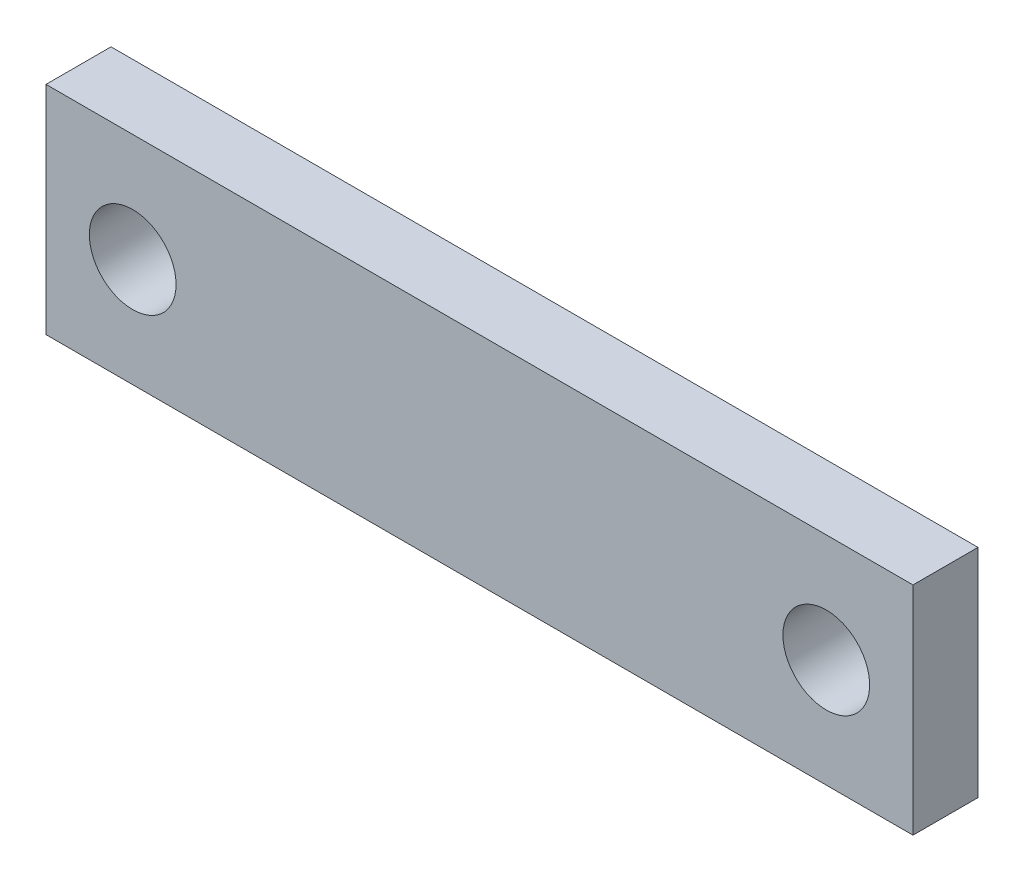
from build123d import *

# Parameters (mm, degrees)
SKETCH1_W           = 20
SKETCH1_H           = 5
SKETCH1_R           = 1
BOSS_EXTRUDE1_DEPTH = 1.5


with BuildPart() as part:
    # Sketch1 → Boss-Extrude1 (new body)
    with BuildSketch(Plane.XY):
        Rectangle(SKETCH1_W, SKETCH1_H)
        with Locations((-8, 0)):
            Circle(SKETCH1_R, mode=Mode.SUBTRACT)
        with Locations((8, 0)):
            Circle(SKETCH1_R, mode=Mode.SUBTRACT)
    extrude(amount=BOSS_EXTRUDE1_DEPTH)


solid = part.part
